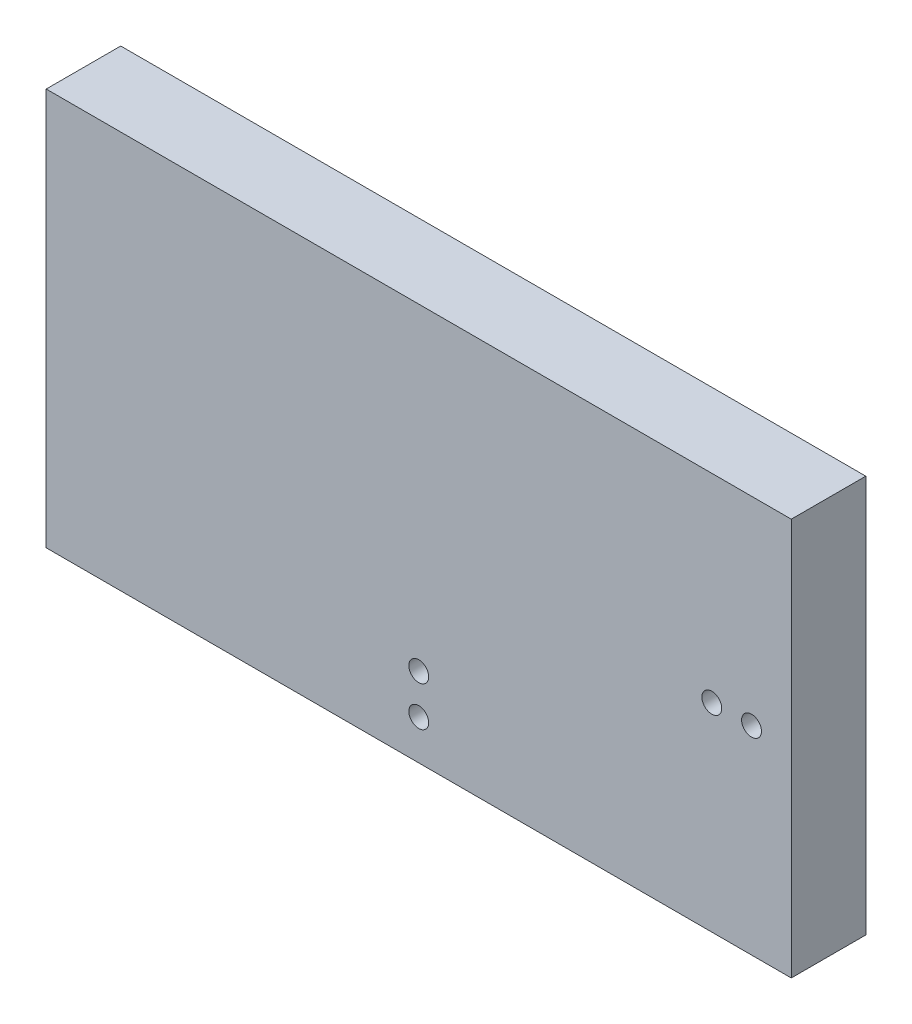
from build123d import *

# Parameters (mm, degrees)
ESQUISSE2_W      = 150
ESQUISSE2_H      = 80
EXTRUSION1_DEPTH = 15
ESQUISSE3_R      = 1.997583562
ESQUISSE3_R_2    = 2
EXTRUSION2_DEPTH = 10


with BuildPart() as part:
    # Esquisse2 → Extrusion1 (new body)
    with BuildSketch(Plane.XY):
        with Locations((-13.733655387, 14.722576177)):
            Rectangle(ESQUISSE2_W, ESQUISSE2_H)
    extrude(amount=-EXTRUSION1_DEPTH)

    # Esquisse3 → Extrusion2 (cut)
    with BuildSketch(Plane.XY):
        with Locations((-13.733655387, -17.277423823)):
            Circle(ESQUISSE3_R)
        with Locations((-13.733655387, -9.277423823)):
            Circle(ESQUISSE3_R_2)
        with Locations((53.266344613, 14.722576177)):
            Circle(ESQUISSE3_R_2)
        with Locations((45.266344613, 14.722576177)):
            Circle(ESQUISSE3_R_2)
    extrude(amount=-EXTRUSION2_DEPTH, mode=Mode.SUBTRACT)


solid = part.part
